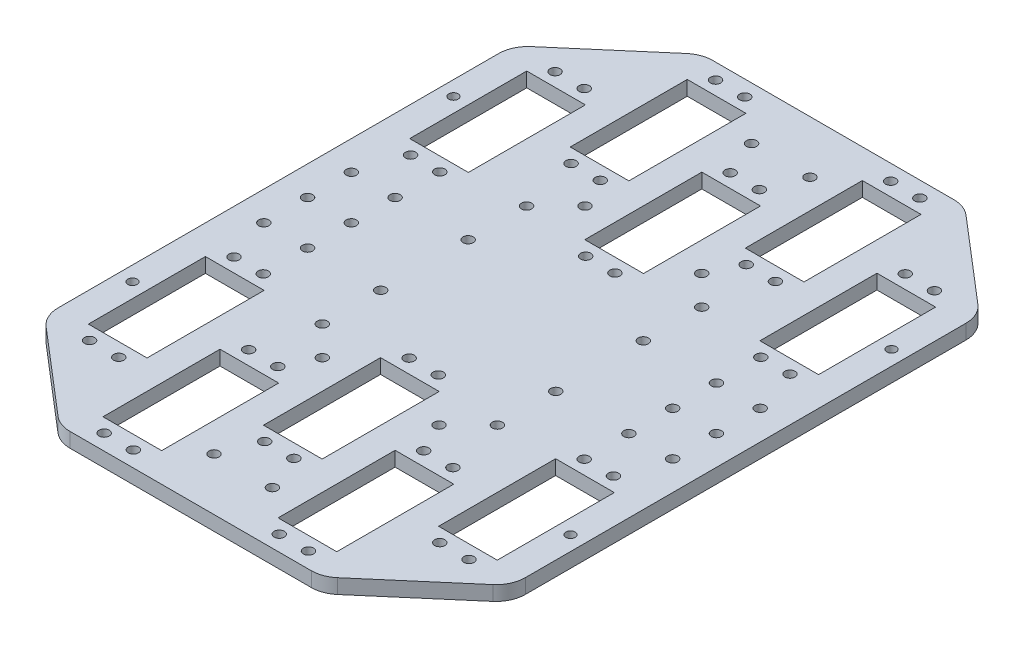
from build123d import *

# Parameters (mm, degrees)
SKETCH_1_W               = 160.1
SKETCH_1_H               = 85.1
SKETCH_1_W_2             = 20.1
SKETCH_1_H_2             = 40.1
EXTRUDE_1_DEPTH          = 5
CUT_EXTRUDE_1_DEPTH      = 1
CUT_EXTRUDE_1_DEPTH_BACK = 6
SKETCH_3_R               = 1.75
CUT_EXTRUDE_2_DEPTH      = 6
SKETCH_4_R               = 1.75
CUT_EXTRUDE_3_DEPTH      = 6
SKETCH_5_R               = 1.75
CUT_EXTRUDE_4_DEPTH      = 6
SKETCH_6_W               = 160.1
SKETCH_6_H               = 50
EXTRUDE_2_DEPTH          = 5
SKETCH_7_R               = 1.75
CUT_EXTRUDE_5_DEPTH      = 6
SKETCH_8_R               = 1.75
SKETCH_8_R_2             = 1.6
CUT_EXTRUDE_6_DEPTH      = 6
FILLET_1_R               = 10


with BuildPart() as part:
    # ｽｹｯﾁ1 → ﾎﾞｽ - 押し出し1 (new body)
    with BuildSketch(Plane(origin=(0, 0, 0), x_dir=(1, 0, 0), z_dir=(0, 1, 0))):
        with Locations((0, 42.55)):
            Rectangle(SKETCH_1_W, SKETCH_1_H)
        with Locations((0, 30.05)):
            Rectangle(SKETCH_1_W_2, SKETCH_1_H_2, mode=Mode.SUBTRACT)
        with Locations((60, 30.05)):
            Rectangle(SKETCH_1_W_2, SKETCH_1_H_2, mode=Mode.SUBTRACT)
        with Locations((30, 55.05)):
            Rectangle(SKETCH_1_W_2, SKETCH_1_H_2, mode=Mode.SUBTRACT)
        with Locations((-60, 30.05)):
            Rectangle(SKETCH_1_W_2, SKETCH_1_H_2, mode=Mode.SUBTRACT)
        with Locations((-30, 55.05)):
            Rectangle(SKETCH_1_W_2, SKETCH_1_H_2, mode=Mode.SUBTRACT)
    extrude(amount=EXTRUDE_1_DEPTH)

    # ｽｹｯﾁ2 → ｶｯﾄ - 押し出し1 (cut, two sides)
    with BuildSketch(Plane(origin=(0, 5, 0), x_dir=(1, 0, 0), z_dir=(0, 1, 0))) as cut_extrude_1_sk:
        Polygon((45.05, 85.1), (80.05, 55.1), (80.05, 85.1), align=None)
        Polygon((-80.05, 55.1), (-45.05, 85.1), (-80.05, 85.1), align=None)
    extrude(amount=CUT_EXTRUDE_1_DEPTH, mode=Mode.SUBTRACT)
    extrude(cut_extrude_1_sk.sketch, amount=-CUT_EXTRUDE_1_DEPTH_BACK, mode=Mode.SUBTRACT)

    # ｽｹｯﾁ3 → ｶｯﾄ - 押し出し2 (cut, through all)
    with BuildSketch(Plane(origin=(0, 5, 0), x_dir=(1, 0, 0), z_dir=(0, 1, 0))):
        with Locations((65, 5.25)):
            Circle(SKETCH_3_R)
        with Locations((55, 5.25)):
            Circle(SKETCH_3_R)
        with Locations((5, 5.25)):
            Circle(SKETCH_3_R)
        with Locations((-5, 5.25)):
            Circle(SKETCH_3_R)
        with Locations((-55, 5.25)):
            Circle(SKETCH_3_R)
        with Locations((-65, 5.25)):
            Circle(SKETCH_3_R)
        with Locations((-35, 79.75)):
            Circle(SKETCH_3_R)
        with Locations((-25, 79.75)):
            Circle(SKETCH_3_R)
        with Locations((25, 79.75)):
            Circle(SKETCH_3_R)
        with Locations((35, 79.75)):
            Circle(SKETCH_3_R)
        with Locations((65, 54.75)):
            Circle(SKETCH_3_R)
        with Locations((55, 54.75)):
            Circle(SKETCH_3_R)
        with Locations((5, 54.75)):
            Circle(SKETCH_3_R)
        with Locations((-5, 54.75)):
            Circle(SKETCH_3_R)
        with Locations((-55, 54.75)):
            Circle(SKETCH_3_R)
        with Locations((-65, 54.75)):
            Circle(SKETCH_3_R)
        with Locations((-35, 30.25)):
            Circle(SKETCH_3_R)
        with Locations((-25, 30.25)):
            Circle(SKETCH_3_R)
        with Locations((25, 30.25)):
            Circle(SKETCH_3_R)
        with Locations((35, 30.25)):
            Circle(SKETCH_3_R)
    extrude(amount=-CUT_EXTRUDE_2_DEPTH, mode=Mode.SUBTRACT)

    # ｽｹｯﾁ4 → ｶｯﾄ - 押し出し3 (cut, through all)
    with BuildSketch(Plane(origin=(0, 5, 0), x_dir=(1, 0, 0), z_dir=(0, 1, 0))):
        with Locations((30, 10)):
            Circle(SKETCH_4_R)
        with Locations((-30, 10)):
            Circle(SKETCH_4_R)
        with Locations((20, 20)):
            Circle(SKETCH_4_R)
        with Locations((-20, 20)):
            Circle(SKETCH_4_R)
    extrude(amount=-CUT_EXTRUDE_3_DEPTH, mode=Mode.SUBTRACT)

    # ｽｹｯﾁ5 → ｶｯﾄ - 押し出し4 (cut, through all)
    with BuildSketch(Plane(origin=(0, 5, 0), x_dir=(1, 0, 0), z_dir=(0, 1, 0))):
        with Locations((-10, 67.1)):
            Circle(SKETCH_5_R)
        with Locations((10, 67.1)):
            Circle(SKETCH_5_R)
    extrude(amount=-CUT_EXTRUDE_4_DEPTH, mode=Mode.SUBTRACT)


with BuildPart() as body_2:
    # ﾐﾗｰ2: mirrored copy
    add(part.part.mirror(Plane.XY.offset(25)))


with BuildPart() as part_1:
    add(part.part)

    add(body_2.part)  # ﾎﾞｽ - 押し出し2 merges body 2
    # ｽｹｯﾁ6 → ﾎﾞｽ - 押し出し2 (add)
    with BuildSketch(Plane(origin=(0, 5, 0), x_dir=(1, 0, 0), z_dir=(0, 1, 0))):
        with Locations((0, -25)):
            Rectangle(SKETCH_6_W, SKETCH_6_H)
    extrude(amount=-EXTRUDE_2_DEPTH)

    # ｽｹｯﾁ7 → ｶｯﾄ - 押し出し5 (cut, through all)
    with BuildSketch(Plane(origin=(0, 5, 0), x_dir=(1, 0, 0), z_dir=(0, 1, 0))):
        with Locations((-30, -10)):
            Circle(SKETCH_7_R)
        with Locations((-30, -40)):
            Circle(SKETCH_7_R)
        with Locations((30, -40)):
            Circle(SKETCH_7_R)
        with Locations((30, -10)):
            Circle(SKETCH_7_R)
    extrude(amount=-CUT_EXTRUDE_5_DEPTH, mode=Mode.SUBTRACT)

    # ｽｹｯﾁ8 → ｶｯﾄ - 押し出し6 (cut, through all)
    with BuildSketch(Plane(origin=(0, 5, 0), x_dir=(1, 0, 0), z_dir=(0, 1, 0))):
        with Locations((-70.05, -25)):
            Circle(SKETCH_8_R)
        with Locations((-70.05, -40)):
            Circle(SKETCH_8_R)
        with Locations((-70.05, -10)):
            Circle(SKETCH_8_R)
        with Locations((70.05, -40)):
            Circle(SKETCH_8_R)
        with Locations((70.05, -25)):
            Circle(SKETCH_8_R)
        with Locations((70.05, -10)):
            Circle(SKETCH_8_R)
        with Locations((-75.05, -80)):
            Circle(SKETCH_8_R_2)
        with Locations((-75.05, 30)):
            Circle(SKETCH_8_R_2)
        with Locations((75.05, -80)):
            Circle(SKETCH_8_R_2)
        with Locations((75.05, 30)):
            Circle(SKETCH_8_R_2)
        with Locations((-55.05, -10)):
            Circle(SKETCH_8_R)
        with Locations((-55.05, -25)):
            Circle(SKETCH_8_R)
        with Locations((-55.05, -40)):
            Circle(SKETCH_8_R)
        with Locations((55.05, -10)):
            Circle(SKETCH_8_R)
        with Locations((55.05, -25)):
            Circle(SKETCH_8_R)
        with Locations((55.05, -40)):
            Circle(SKETCH_8_R)
    extrude(amount=-CUT_EXTRUDE_6_DEPTH, mode=Mode.SUBTRACT)

    # ﾌｨﾚｯﾄ1
    fillet_1_edges = [part_1.edges().sort_by_distance(p)[0] for p in [
        (45.05, 2.5, -85.1),
        (-45.05, 2.5, -85.1),
        (-80.05, 2.5, -55.1),
        (80.05, 2.5, -55.1),
        (-80.05, 2.5, 105.1),
        (45.05, 2.5, 135.1),
        (80.05, 2.5, 105.1),
        (-45.05, 2.5, 135.1),
    ]]
    fillet(fillet_1_edges, radius=FILLET_1_R)


solid = part_1.part
